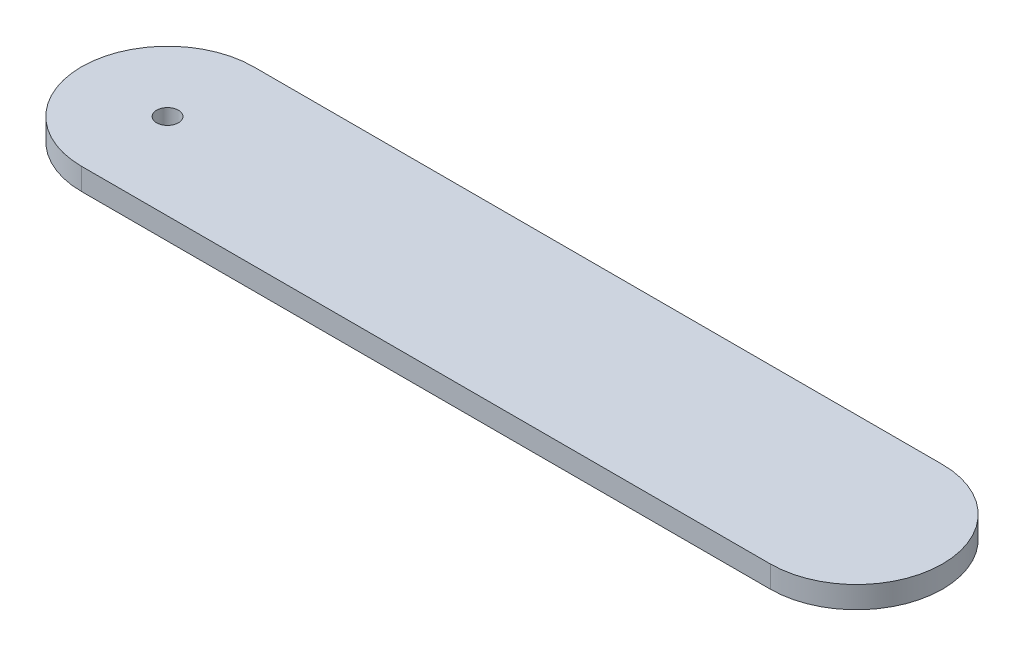
from build123d import *

# Parameters (mm, degrees)
BOSS_EXTRUDE1_DEPTH = 6.35
SKETCH4_R           = 3.175
CUT_EXTRUDE1_DEPTH  = 7.35


with BuildPart() as part:
    # Sketch2 → Boss-Extrude1 (new body)
    with BuildSketch(Plane(origin=(0, 0, 0), x_dir=(1, 0, 0), z_dir=(0, 1, 0))):
        with BuildLine():
            Line((0, 25), (200, 25))
            ThreePointArc((200, 25), (225, 0), (200, -25))
            Line((200, -25), (0, -25))
            ThreePointArc((0, -25), (-25, 0), (0, 25))
        make_face()
    extrude(amount=BOSS_EXTRUDE1_DEPTH)

    # Sketch4 → Cut-Extrude1 (cut, through all)
    with BuildSketch(Plane(origin=(0, 6.35, 0), x_dir=(1, 0, 0), z_dir=(0, 1, 0))):
        Circle(SKETCH4_R)
    extrude(amount=-CUT_EXTRUDE1_DEPTH, mode=Mode.SUBTRACT)


solid = part.part
